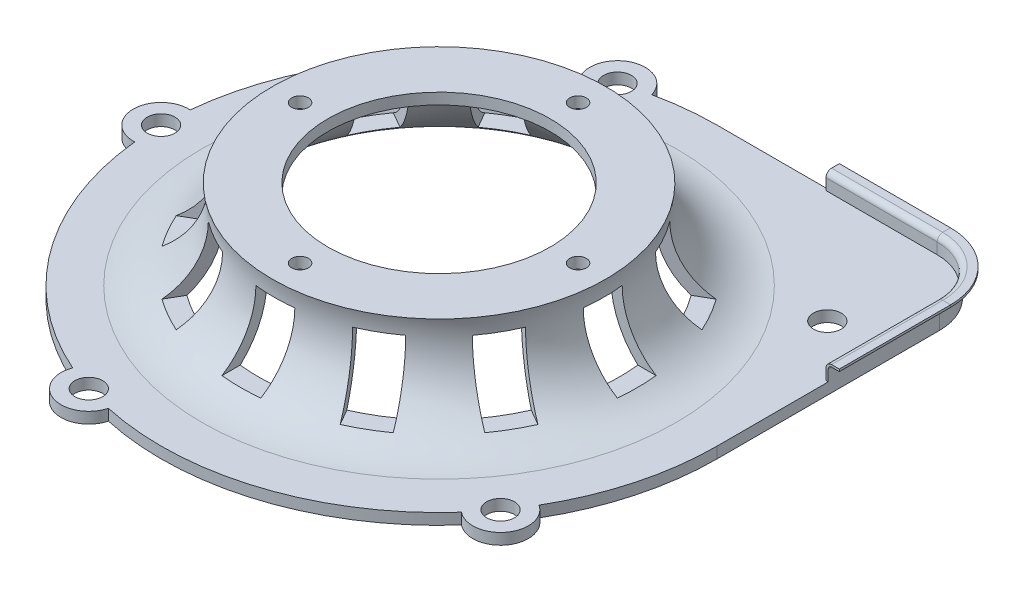
from build123d import *

# Parameters (mm, degrees)
BOSS_EXTRUDE1_DEPTH = 10
CUT_EXTRUDE2_START  = 137.133449
SKETCH6_W           = 35
SKETCH6_H           = 55
CUT_EXTRUDE2_DEPTH  = 41.471088
CIRPATTERN1_COUNT   = 11
CIRPATTERN1_ANGLE   = 300
SKETCH8_R           = 7.5
CUT_EXTRUDE4_DEPTH  = 10
CUT_EXTRUDE5_REACH  = 12
SKETCH9_R           = 12.5


with BuildPart() as part:
    # Sketch1 → Revolve1 (revolve)
    with BuildSketch(Plane.XY, mode=Mode.PRIVATE) as revolve1_sk:
        with BuildLine():
            Line((100, 90), (100, 80))
            Line((100, 80), (138.412405468, 80))
            ThreePointArc((138.412405468, 80), (158.473297453, 23.76524617), (213.245553203, 0))
            Line((213.245553203, 0), (250, 0))
            Line((250, 0), (250, 10))
            Line((250, 10), (213.245553203, 10))
            ThreePointArc((213.245553203, 10), (162.255358067, 34.688711259), (150, 90))
            Line((150, 90), (100, 90))
        make_face()
    revolve(revolve1_sk.sketch.rotate(Axis((0, 63.768203856, 0), (0, -1, 0)), 90), axis=Axis((0, 63.768203856, 0), (0, -1, 0)))  # turned: the seam where the file's is

    # Sketch3 → Boss-Extrude1 (add)
    with BuildSketch(Plane.XZ):
        with BuildLine():
            Line((250, -200), (250, 0))
            ThreePointArc((250, 0), (176.776695297, -176.776695297), (0, -250))
            Line((0, -250), (200, -250))
            ThreePointArc((200, -250), (235.355339059, -235.355339059), (250, -200))
        make_face()
        with BuildLine():
            ThreePointArc((-248.75, 24.968730444), (-275, 0), (-248.75, -24.968730444))
            ThreePointArc((-248.75, -24.968730444), (-250, 0), (-248.75, 24.968730444))
        make_face()
        with BuildLine():
            ThreePointArc((-53.121303558, 244.291070464), (-84.979673453, 261.540541981), (-100.614651143, 228.859546393))
            ThreePointArc((-100.614651143, 228.859546393), (-77.254248594, 237.764129074), (-53.121303558, 244.291070464))
        make_face()
        with BuildLine():
            ThreePointArc((215.919228874, 126.01145425), (222.479673453, 161.64094438), (186.566725827, 166.411708765))
            ThreePointArc((186.566725827, 166.411708765), (202.254248594, 146.946313073), (215.919228874, 126.01145425))
        make_face()
        with BuildLine():
            ThreePointArc((-100.614651143, -228.859546393), (-84.979673453, -261.540541981), (-53.121303558, -244.291070464))
            ThreePointArc((-53.121303558, -244.291070464), (-77.254248594, -237.764129074), (-100.614651143, -228.859546393))
        make_face()
    extrude(amount=-BOSS_EXTRUDE1_DEPTH)

    # Sketch6 → Cut-Extrude2 (cut)
    with BuildSketch(Plane(origin=(0, 0, 0), x_dir=(-1, 0, 0), z_dir=(0, 0, -1)).offset(CUT_EXTRUDE2_START)):
        with Locations((0, 47.5)):
            Rectangle(SKETCH6_W, SKETCH6_H)
    cut_extrude2 = extrude(amount=CUT_EXTRUDE2_DEPTH, mode=Mode.SUBTRACT)

    # CirPattern1: Cut-Extrude2 ×11 about axis
    cirpattern1_axis = Axis((0, 0, 0), (0, 1, 0))
    for i in range(1, CIRPATTERN1_COUNT):
        add(cut_extrude2.rotate(cirpattern1_axis, i * CIRPATTERN1_ANGLE / (CIRPATTERN1_COUNT - 1)), mode=Mode.SUBTRACT)

    # Sketch8 → Cut-Extrude4 (cut)
    with BuildSketch(Plane(origin=(0, 90, 0), x_dir=(1, 0, 0), z_dir=(0, 1, 0))):
        with Locations(Location((0, 125, 0), (0, 0, 270))):  # turned: the seam where the file's is
            Circle(SKETCH8_R)
        with Locations(Location((125, 0, 0), (0, 0, 270))):  # turned: the seam where the file's is
            Circle(SKETCH8_R)
        with Locations(Location((0, -125, 0), (0, 0, 270))):  # turned: the seam where the file's is
            Circle(SKETCH8_R)
        with Locations(Location((-125, 0, 0), (0, 0, 270))):  # turned: the seam where the file's is
            Circle(SKETCH8_R)
    extrude(amount=-CUT_EXTRUDE4_DEPTH, mode=Mode.SUBTRACT)

    # Sketch9 → Cut-Extrude5 (cut, up to next)
    with BuildSketch(Plane(origin=(0, 10, 0), x_dir=(1, 0, 0), z_dir=(0, 1, 0)), mode=Mode.PRIVATE) as cut_extrude5_sk1:
        with Locations(Location((-77.254248594, 237.764129074, 0), (0, 0, 270))):  # turned: the seam where the file's is
            Circle(SKETCH9_R)
    cut_extrude5_tool1 = extrude(cut_extrude5_sk1.sketch, amount=-CUT_EXTRUDE5_REACH, mode=Mode.PRIVATE) & part.part
    add(cut_extrude5_tool1.solids().sort_by_distance((-77.254249, 10, -237.764129))[0], mode=Mode.SUBTRACT)
    # Sketch9 → Cut-Extrude5 (cut, up to next)
    with BuildSketch(Plane(origin=(0, 10, 0), x_dir=(1, 0, 0), z_dir=(0, 1, 0)), mode=Mode.PRIVATE) as cut_extrude5_sk2:
        with Locations(Location((202.254248594, 146.946313073, 0), (0, 0, 270))):  # turned: the seam where the file's is
            Circle(SKETCH9_R)
    cut_extrude5_tool2 = extrude(cut_extrude5_sk2.sketch, amount=-CUT_EXTRUDE5_REACH, mode=Mode.PRIVATE) & part.part
    add(cut_extrude5_tool2.solids().sort_by_distance((202.254249, 10, -146.946313))[0], mode=Mode.SUBTRACT)
    # Sketch9 → Cut-Extrude5 (cut, up to next)
    with BuildSketch(Plane(origin=(0, 10, 0), x_dir=(1, 0, 0), z_dir=(0, 1, 0)), mode=Mode.PRIVATE) as cut_extrude5_sk3:
        with Locations(Location((202.254248594, -146.946313073, 0), (0, 0, 270))):  # turned: the seam where the file's is
            Circle(SKETCH9_R)
    cut_extrude5_tool3 = extrude(cut_extrude5_sk3.sketch, amount=-CUT_EXTRUDE5_REACH, mode=Mode.PRIVATE) & part.part
    add(cut_extrude5_tool3.solids().sort_by_distance((202.254249, 10, 146.946313))[0], mode=Mode.SUBTRACT)
    # Sketch9 → Cut-Extrude5 (cut, up to next)
    with BuildSketch(Plane(origin=(0, 10, 0), x_dir=(1, 0, 0), z_dir=(0, 1, 0)), mode=Mode.PRIVATE) as cut_extrude5_sk4:
        with Locations(Location((-77.254248594, -237.764129074, 0), (0, 0, 270))):  # turned: the seam where the file's is
            Circle(SKETCH9_R)
    cut_extrude5_tool4 = extrude(cut_extrude5_sk4.sketch, amount=-CUT_EXTRUDE5_REACH, mode=Mode.PRIVATE) & part.part
    add(cut_extrude5_tool4.solids().sort_by_distance((-77.254249, 10, 237.764129))[0], mode=Mode.SUBTRACT)
    # Sketch9 → Cut-Extrude5 (cut, up to next)
    with BuildSketch(Plane(origin=(0, 10, 0), x_dir=(1, 0, 0), z_dir=(0, 1, 0)), mode=Mode.PRIVATE) as cut_extrude5_sk5:
        with Locations(Location((-250, 0, 0), (0, 0, 270))):  # turned: the seam where the file's is
            Circle(SKETCH9_R)
    cut_extrude5_tool5 = extrude(cut_extrude5_sk5.sketch, amount=-CUT_EXTRUDE5_REACH, mode=Mode.PRIVATE) & part.part
    add(cut_extrude5_tool5.solids().sort_by_distance((-250, 10, 0))[0], mode=Mode.SUBTRACT)

    # Sweep1: sweep along a path in Sketch11
    with BuildLine(Plane(origin=(0, 10, 0), x_dir=(1, 0, 0), z_dir=(0, 1, 0))) as sweep1_path:
        Line((250, 100), (250, 200))
        ThreePointArc((250, 200), (235.355339059, 235.355339059), (200, 250))
        Line((200, 250), (100, 250))
    # Sketch10 → Sweep1 (sweep)
    with BuildSketch(Plane(origin=(0, 0, -100), x_dir=(-1, 0, 0), z_dir=(0, 0, -1))):
        with BuildLine():
            Line((-253, 23), (-260, 23))
            Line((-260, 23), (-260, 25))
            Line((-260, 25), (-253, 25))
            ThreePointArc((-253, 25), (-249.464466094, 23.535533906), (-248, 20))
            Line((-248, 20), (-248, 10))
            Line((-248, 10), (-250, 10))
            Line((-250, 10), (-250, 20))
            ThreePointArc((-250, 20), (-250.878679656, 22.121320344), (-253, 23))
        make_face()
    sweep(path=sweep1_path.line)


solid = part.part
